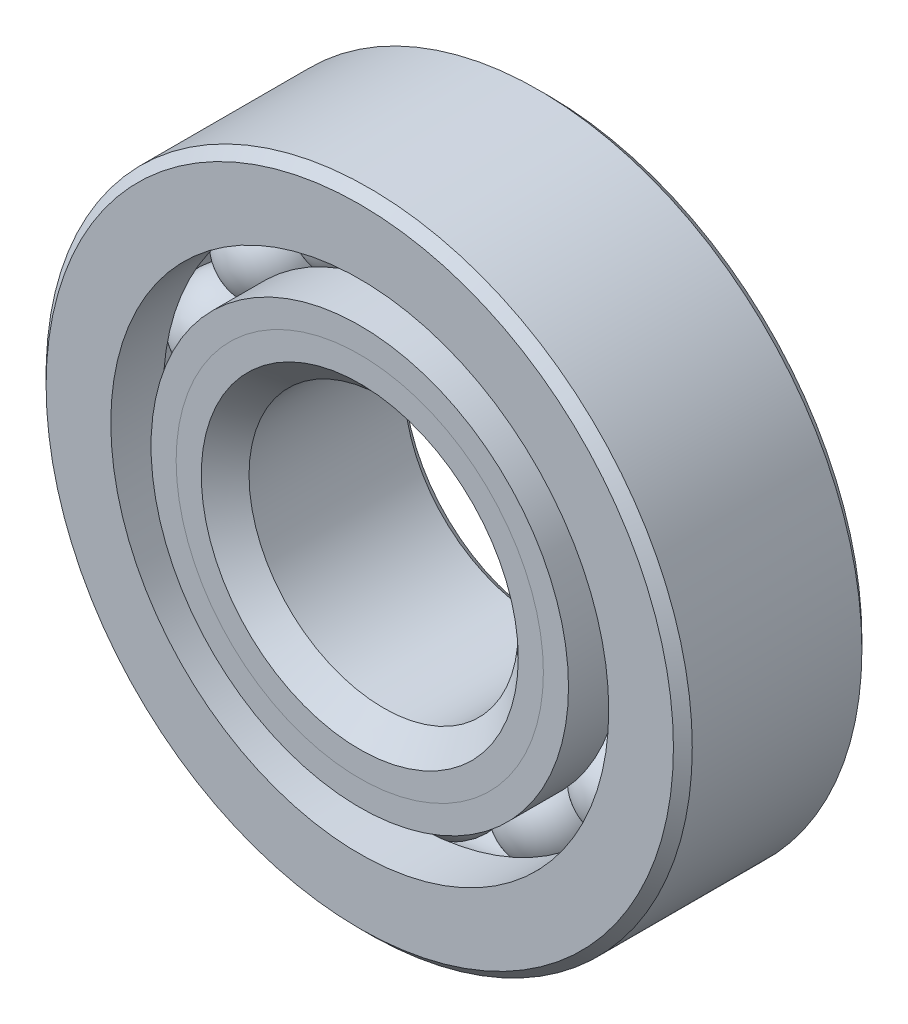
from build123d import *

# Parameters (mm, degrees)
CIRPATTERN1_COUNT = 14


with BuildPart() as part:
    # Sketch1 → Revolve1 (revolve)
    with BuildSketch(Plane(origin=(0, 0, 0), x_dir=(0, 0, -1), z_dir=(1, 0, 0))):
        with BuildLine():
            Line((5.000625, 19.05), (-5.000625, 19.05))
            Line((-5.000625, 19.05), (-5.55625, 18.494375))
            Line((-5.55625, 18.494375), (-5.55625, 14.680013736))
            Line((-5.55625, 14.680013736), (-2.469444444, 14.680013736))
            ThreePointArc((-2.469444444, 14.680013736), (0, 16.233344407), (2.469444444, 14.680013736))
            Line((2.469444444, 14.680013736), (5.55625, 14.680013736))
            Line((5.55625, 14.680013736), (5.55625, 18.494375))
            Line((5.55625, 18.494375), (5.000625, 19.05))
        make_face()
    revolve(axis=Axis((0, 0, 5.55625), (0, 0, -1)))


with BuildPart() as body_2:
    # Sketch2 → Revolve2 (revolve)
    with BuildSketch(Plane(origin=(0, 0, 0), x_dir=(0, 0, -1), z_dir=(1, 0, 0))):
        with BuildLine():
            Line((-5.55625, 12.307486264), (-2.469444444, 12.307486264))
            ThreePointArc((-2.469444444, 12.307486264), (-1.458680229, 11.174778351), (0, 10.754155593))
            Line((0, 10.754155593), (0, 9.345827796))
            Line((0, 9.345827796), (-4.075420766, 9.345827796))
            Line((-4.075420766, 9.345827796), (-5.55625, 10.82665703))
            Line((-5.55625, 10.82665703), (-5.55625, 12.307486264))
        make_face()
    revolve(axis=Axis((0, 0, 5.55625), (0, 0, -1)))


with BuildPart() as body_3:
    # Sketch3 → Revolve3 (revolve)
    with BuildSketch(Plane(origin=(0, 0, 0), x_dir=(0, 0, -1), z_dir=(1, 0, 0))):
        with BuildLine():
            Line((-5.55625, 10.82665703), (-4.075420766, 9.345827796))
            Line((-4.075420766, 9.345827796), (0, 9.345827796))
            Line((0, 9.345827796), (0, 10.754155593))
            ThreePointArc((0, 10.754155593), (1.458680229, 11.174778351), (2.469444444, 12.307486264))
            Line((2.469444444, 12.307486264), (5.55625, 12.307486264))
            Line((5.55625, 12.307486264), (5.55625, 8.493125))
            Line((5.55625, 8.493125), (5.000625, 7.9375))
            Line((5.000625, 7.9375), (-4.147922204, 7.9375))
            Line((-4.147922204, 7.9375), (-5.55625, 9.345827796))
            Line((-5.55625, 9.345827796), (-5.55625, 10.82665703))
        make_face()
    revolve(axis=Axis((0, 0, 5.55625), (0, 0, -1)))


with BuildPart() as body_4:
    # Sketch4 → Revolve4 (revolve)
    with BuildSketch(Plane(origin=(0, 0, 0), x_dir=(0, 0, -1), z_dir=(1, 0, 0))):
        with BuildLine():
            Line((-2.739594407, 13.49375), (2.739594407, 13.49375))
            ThreePointArc((2.739594407, 13.49375), (0, 16.233344407), (-2.739594407, 13.49375))
        make_face()
    revolve(axis=Axis((0, 13.49375, 2.739594407), (0, 0, -1)))


with BuildPart() as cirpattern1_1:
    # CirPattern1: pattern copy
    add(body_4.part.rotate(Axis((0, 0, -5.55625), (0, 0, 1)), 1 * 360 / CIRPATTERN1_COUNT))


with BuildPart() as cirpattern1_2:
    # CirPattern1: pattern copy
    add(body_4.part.rotate(Axis((0, 0, -5.55625), (0, 0, 1)), 2 * 360 / CIRPATTERN1_COUNT))


with BuildPart() as cirpattern1_3:
    # CirPattern1: pattern copy
    add(body_4.part.rotate(Axis((0, 0, -5.55625), (0, 0, 1)), 3 * 360 / CIRPATTERN1_COUNT))


with BuildPart() as cirpattern1_4:
    # CirPattern1: pattern copy
    add(body_4.part.rotate(Axis((0, 0, -5.55625), (0, 0, 1)), 4 * 360 / CIRPATTERN1_COUNT))


with BuildPart() as cirpattern1_5:
    # CirPattern1: pattern copy
    add(body_4.part.rotate(Axis((0, 0, -5.55625), (0, 0, 1)), 5 * 360 / CIRPATTERN1_COUNT))


with BuildPart() as cirpattern1_6:
    # CirPattern1: pattern copy
    add(body_4.part.rotate(Axis((0, 0, -5.55625), (0, 0, 1)), 6 * 360 / CIRPATTERN1_COUNT))


with BuildPart() as cirpattern1_7:
    # CirPattern1: pattern copy
    add(body_4.part.rotate(Axis((0, 0, -5.55625), (0, 0, 1)), 7 * 360 / CIRPATTERN1_COUNT))


with BuildPart() as cirpattern1_8:
    # CirPattern1: pattern copy
    add(body_4.part.rotate(Axis((0, 0, -5.55625), (0, 0, 1)), 8 * 360 / CIRPATTERN1_COUNT))


with BuildPart() as cirpattern1_9:
    # CirPattern1: pattern copy
    add(body_4.part.rotate(Axis((0, 0, -5.55625), (0, 0, 1)), 9 * 360 / CIRPATTERN1_COUNT))


with BuildPart() as cirpattern1_10:
    # CirPattern1: pattern copy
    add(body_4.part.rotate(Axis((0, 0, -5.55625), (0, 0, 1)), 10 * 360 / CIRPATTERN1_COUNT))


with BuildPart() as cirpattern1_11:
    # CirPattern1: pattern copy
    add(body_4.part.rotate(Axis((0, 0, -5.55625), (0, 0, 1)), 11 * 360 / CIRPATTERN1_COUNT))


with BuildPart() as cirpattern1_12:
    # CirPattern1: pattern copy
    add(body_4.part.rotate(Axis((0, 0, -5.55625), (0, 0, 1)), 12 * 360 / CIRPATTERN1_COUNT))


with BuildPart() as cirpattern1_13:
    # CirPattern1: pattern copy
    add(body_4.part.rotate(Axis((0, 0, -5.55625), (0, 0, 1)), 13 * 360 / CIRPATTERN1_COUNT))


solid = Compound([part.part, body_2.part, body_3.part, body_4.part, cirpattern1_1.part, cirpattern1_2.part, cirpattern1_3.part, cirpattern1_4.part, cirpattern1_5.part, cirpattern1_6.part, cirpattern1_7.part, cirpattern1_8.part, cirpattern1_9.part, cirpattern1_10.part, cirpattern1_11.part, cirpattern1_12.part, cirpattern1_13.part])
